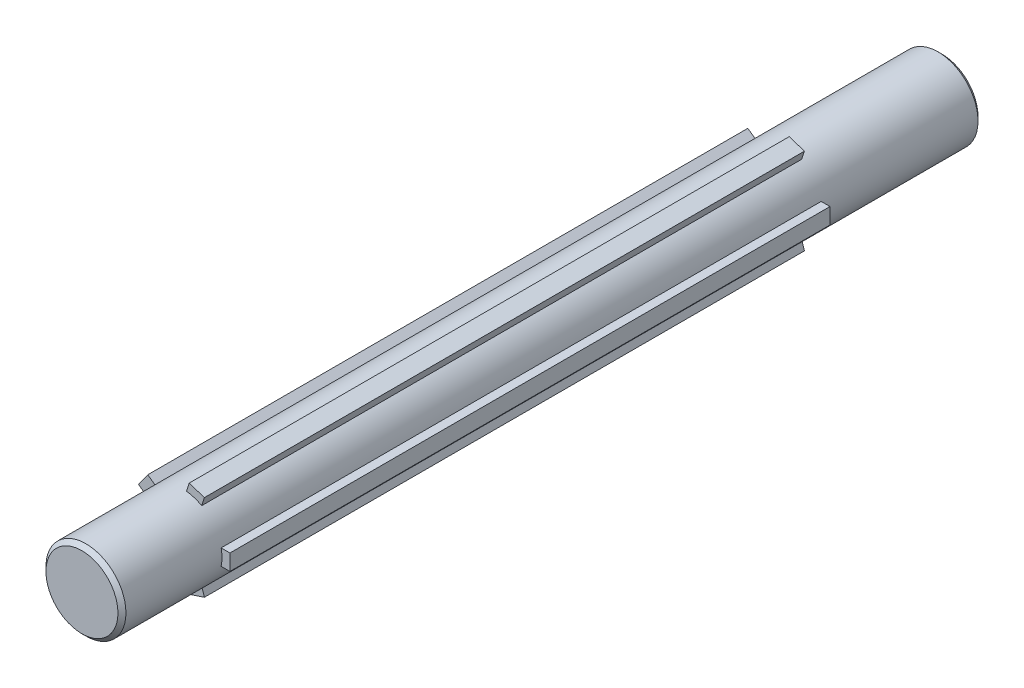
from build123d import *

# Parameters (mm, degrees)
SKETCH1_R           = 10
BOSS_EXTRUDE1_DEPTH = 40
BOSS_EXTRUDE2_START = 40
BOSS_EXTRUDE2_DEPTH = 150
BOSS_EXTRUDE3_START = 190
SKETCH1_4_R         = 10
BOSS_EXTRUDE3_DEPTH = 25
CHAMFER1_SIZE       = 1


with BuildPart() as part:
    # Sketch1 → Boss-Extrude1 (new body)
    with BuildSketch(Plane.XY):
        Circle(SKETCH1_R)
    extrude(amount=BOSS_EXTRUDE1_DEPTH)

    # Sketch1_3 → Boss-Extrude2 (add)
    with BuildSketch(Plane.XY.offset(BOSS_EXTRUDE2_START)):
        with BuildLine():
            ThreePointArc((4.929848865, -8.700378737), (8.090169944, -5.877852523), (9.797958971, -2))
            Line((9.797958971, -2), (12, -2))
            Line((12, -2), (12, 2))
            Line((12, 2), (9.797958971, 2))
            ThreePointArc((9.797958971, 2), (8.090169944, 5.877852523), (4.929848865, 8.700378737))
            Line((4.929848865, 8.700378737), (5.610316965, 10.794644207))
            Line((5.610316965, 10.794644207), (1.8060909, 12.030712184))
            Line((1.8060909, 12.030712184), (1.1256228, 9.936446715))
            ThreePointArc((1.1256228, 9.936446715), (-3.090169944, 9.510565163), (-6.751144813, 7.377129775))
            Line((-6.751144813, 7.377129775), (-8.532633428, 8.671457016))
            Line((-8.532633428, 8.671457016), (-10.883774437, 5.435389039))
            Line((-10.883774437, 5.435389039), (-9.102285822, 4.141061797))
            ThreePointArc((-9.102285822, 4.141061797), (-10, 0), (-9.102285822, -4.141061797))
            Line((-9.102285822, -4.141061797), (-10.883774437, -5.435389039))
            Line((-10.883774437, -5.435389039), (-8.532633428, -8.671457016))
            Line((-8.532633428, -8.671457016), (-6.751144813, -7.377129775))
            ThreePointArc((-6.751144813, -7.377129775), (-3.090169944, -9.510565163), (1.1256228, -9.936446715))
            Line((1.1256228, -9.936446715), (1.8060909, -12.030712184))
            Line((1.8060909, -12.030712184), (5.610316965, -10.794644207))
            Line((5.610316965, -10.794644207), (4.929848865, -8.700378737))
        make_face()
    extrude(amount=BOSS_EXTRUDE2_DEPTH)

    # Sketch1_4 → Boss-Extrude3 (add)
    with BuildSketch(Plane.XY.offset(BOSS_EXTRUDE3_START)):
        Circle(SKETCH1_4_R)
    extrude(amount=BOSS_EXTRUDE3_DEPTH)

    # Chamfer1
    chamfer1_edges = [part.edges().sort_by_distance(p)[0] for p in [
        (-10, 0, 215),
        (-10, 0, 0),
    ]]
    chamfer(chamfer1_edges, length=CHAMFER1_SIZE)


solid = part.part
